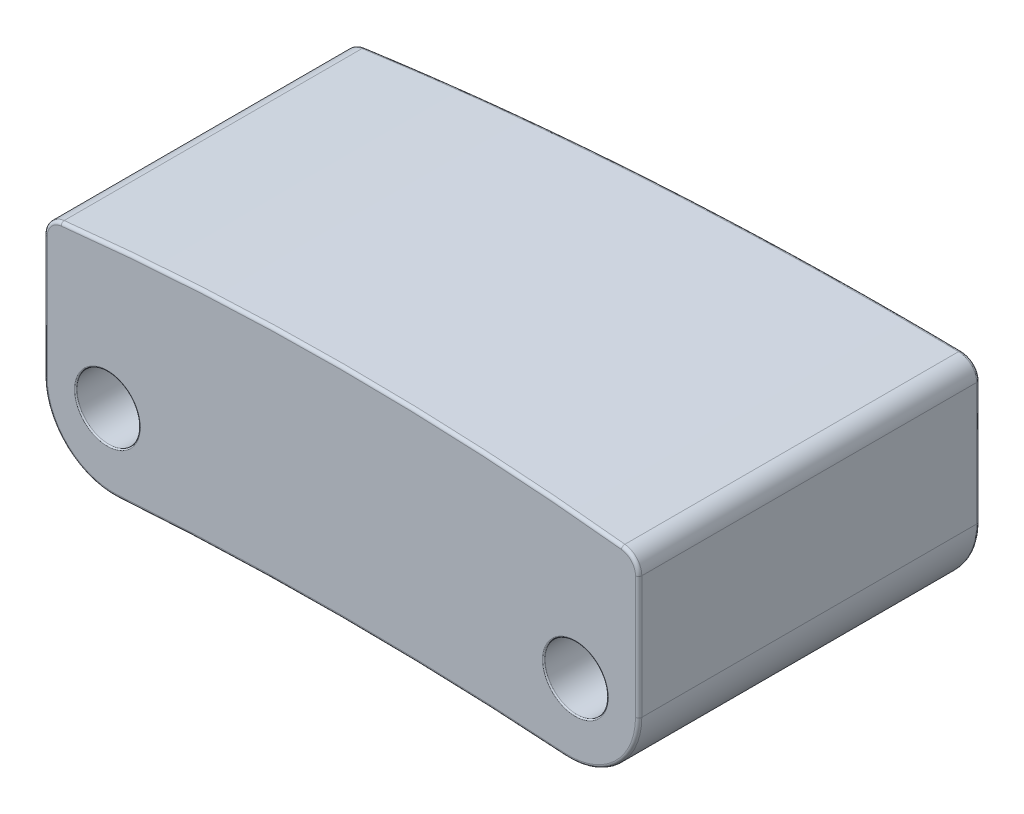
from build123d import *

# Parameters (mm, degrees)
SKETCH1_W               = 9.4
SKETCH1_H               = 3.7
BOSS_EXTRUDE1_DEPTH     = 2.7
CUT_EXTRUDE1_DEPTH      = 15.2
FILLET1_R               = 1.1
FILLET2_R               = 0.3
SKETCH3_R               = 0.5
CUT_EXTRUDE2_DEPTH      = 3
FILLET4_R               = 0.02
CUT_EXTRUDE3_DEPTH      = 5
FILLET5_R               = 0.05
CUT_EXTRUDE4_REACH      = 17.72
CUT_EXTRUDE4_END_RADIUS = 50.4
CUT_EXTRUDE4_START      = -10
SKETCH5_R               = 0.4
FILLET6_R               = 0.05


with BuildPart() as part:
    # Sketch1 → Boss-Extrude1 (new, symmetric)
    with BuildSketch(Plane.XY):
        Rectangle(SKETCH1_W, SKETCH1_H)
    extrude(amount=BOSS_EXTRUDE1_DEPTH, both=True)

    # Sketch2 → Cut-Extrude1 (cut)
    with BuildSketch(Plane.XY.offset(2.7)):
        with BuildLine():
            Line((-4.7, 1.55), (-7.120690005, 4.011417256))
            Line((-7.120690005, 4.011417256), (5.535860742, 3.886722174))
            Line((5.535860742, 3.886722174), (4.7, 1.55))
            ThreePointArc((4.7, 1.55), (0, 1.827084699), (-4.7, 1.55))
        make_face()
        with BuildLine():
            Line((4.7, -1.85), (0.350623614, -3.782025322))
            Line((0.350623614, -3.782025322), (-4.7, -1.85))
            ThreePointArc((-4.7, -1.85), (0, -1.628609864), (4.7, -1.85))
        make_face()
    extrude(amount=-CUT_EXTRUDE1_DEPTH, mode=Mode.SUBTRACT)

    # Fillet1
    fillet1_edges = [part.edges().sort_by_distance(p)[0] for p in [
        (4.7, -1.85, 0),
        (-4.7, -1.85, 0),
    ]]
    fillet(fillet1_edges, radius=FILLET1_R)

    # Fillet2
    fillet2_edges = [part.edges().sort_by_distance(p)[0] for p in [
        (4.7, 1.55, 0),
        (-4.7, 1.55, 0),
    ]]
    fillet(fillet2_edges, radius=FILLET2_R)

    # Sketch3 → Cut-Extrude2 (cut)
    with BuildSketch(Plane.XY.offset(2.7)):
        with Locations((3.7, -0.6)):
            Circle(SKETCH3_R)
        with Locations((-3.7, -0.6)):
            Circle(SKETCH3_R)
    extrude(amount=-CUT_EXTRUDE2_DEPTH, mode=Mode.SUBTRACT)

    # Fillet4
    fillet4_edges = [part.edges().sort_by_distance(p)[0] for p in [
        (3.2, -0.6, 2.7),
        (-4.2, -0.6, 2.7),
    ]]
    fillet(fillet4_edges, radius=FILLET4_R)

    # Sketch4 → Cut-Extrude3 (cut, symmetric)
    with BuildSketch(Plane(origin=(0, 0, 0), x_dir=(1, 0, 0), z_dir=(0, 1, 0))):
        with BuildLine():
            Line((-4.7, 2.1), (-6.612719149, 3.613907535))
            Line((-6.612719149, 3.613907535), (6.420677859, 4.474089961))
            Line((6.420677859, 4.474089961), (4.7, 2.7))
            ThreePointArc((4.7, 2.7), (0.004710726, 2.326198627), (-4.7, 2.1))
        make_face()
    extrude(amount=CUT_EXTRUDE3_DEPTH, both=True, mode=Mode.SUBTRACT)

    # Fillet5
    fillet5_edges = [part.edges().sort_by_distance(p)[0] for p in [
        (4.7, 0.3134624, -2.7),
        (4.7, 0.3134624, 2.7),
        (0, -1.628609864, 2.7),
        (-4.349918456, -1.460327621, 2.7),
        (4.349918456, -1.460327621, 2.7),
        (0, 1.827084699, 2.7),
        (-4.7, 0.3134624, 2.7),
        (-4.623578634, 1.482534062, 2.7),
        (4.623578634, 1.482534062, 2.7),
        (3.2, -0.6, -0.3),
        (-4.623553452, 1.482562201, -2.102492735),
        (4.349071598, -1.461115949, -2.666925627),
        (-4.349757648, -1.460477444, -2.11174073),
        (4.623384041, 1.482751346, -2.692708087),
        (0.004177998, 1.827084481, -2.326164624),
        (0.002641899, -1.628609931, -2.326066603),
        (-4.7, 0.3134624, -2.1),
    ]]
    fillet(fillet5_edges, radius=FILLET5_R)

    # Cut-Extrude4: up to this cylinder (the profile starts inside it)
    cut_extrude4_end = Plane(origin=(0, -51.628609864, 1.2), z_dir=(0, 0, 1)) * Cylinder(CUT_EXTRUDE4_END_RADIUS, 137.24, mode=Mode.PRIVATE)
    # Sketch5 → Cut-Extrude4 (cut, up to the surface)
    with BuildSketch(Plane(origin=(0, 0, 0), x_dir=(1, 0, 0), z_dir=(0, 1, 0)).offset(CUT_EXTRUDE4_START), mode=Mode.PRIVATE) as cut_extrude4_sk1:
        with Locations(Location((-0.7, -1.2, 0), (0, 0, 90))):
            Circle(SKETCH5_R)
    cut_extrude4_tool1 = extrude(cut_extrude4_sk1.sketch, amount=CUT_EXTRUDE4_REACH, mode=Mode.PRIVATE) & cut_extrude4_end
    add(cut_extrude4_tool1.solids().sort_by_distance((-0.7, -10, 1.2))[0], mode=Mode.SUBTRACT)

    # Fillet6
    fillet6_edges = [part.edges().sort_by_distance(p)[0] for p in [
        (-0.700029875, -1.633510522, 1.599999999),
    ]]
    fillet(fillet6_edges, radius=FILLET6_R)


solid = part.part
